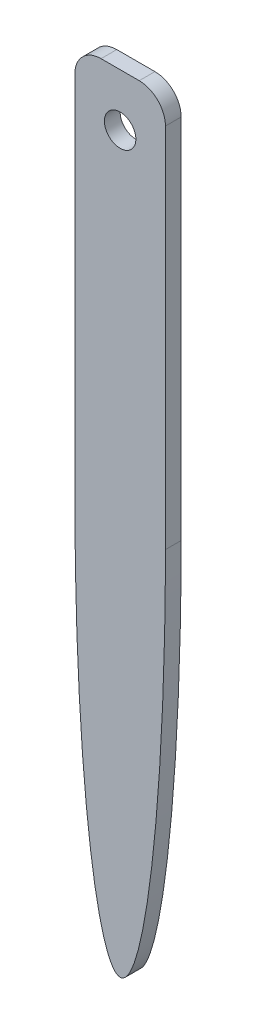
from build123d import *

# Parameters (mm, degrees)
SKETCH_2_R      = 3
EXTRUDE_1_DEPTH = 3


with BuildPart() as part:
    # 草图2 → 凸台-拉伸1 (new body)
    with BuildSketch(Plane.XY):
        with BuildLine():
            Line((-3.641664966, 75), (3.641664966, 75))
            ThreePointArc((3.641664966, 75), (7.177198872, 73.535533906), (8.641664966, 70))
            Line((8.641664966, 70), (8.641664966, 0))
            add(Edge.make_bspline(
                [(-8.641664966, 0), (-8.641664966, -75), (0, -75), (8.641664966, -75), (8.641664966, 0)],
                knots=[4.71238898, 4.71238898, 4.71238898, 6.283185307, 6.283185307, 7.853981634, 7.853981634, 7.853981634], degree=2, weights=[1, 0.707106781, 1, 0.707106781, 1]))
            Line((-8.641664966, 0), (-8.641664966, 70))
            ThreePointArc((-8.641664966, 70), (-7.177198872, 73.535533906), (-3.641664966, 75))
        make_face()
        with Locations((0, 65)):
            Circle(SKETCH_2_R, mode=Mode.SUBTRACT)
    extrude(amount=EXTRUDE_1_DEPTH)


solid = part.part
